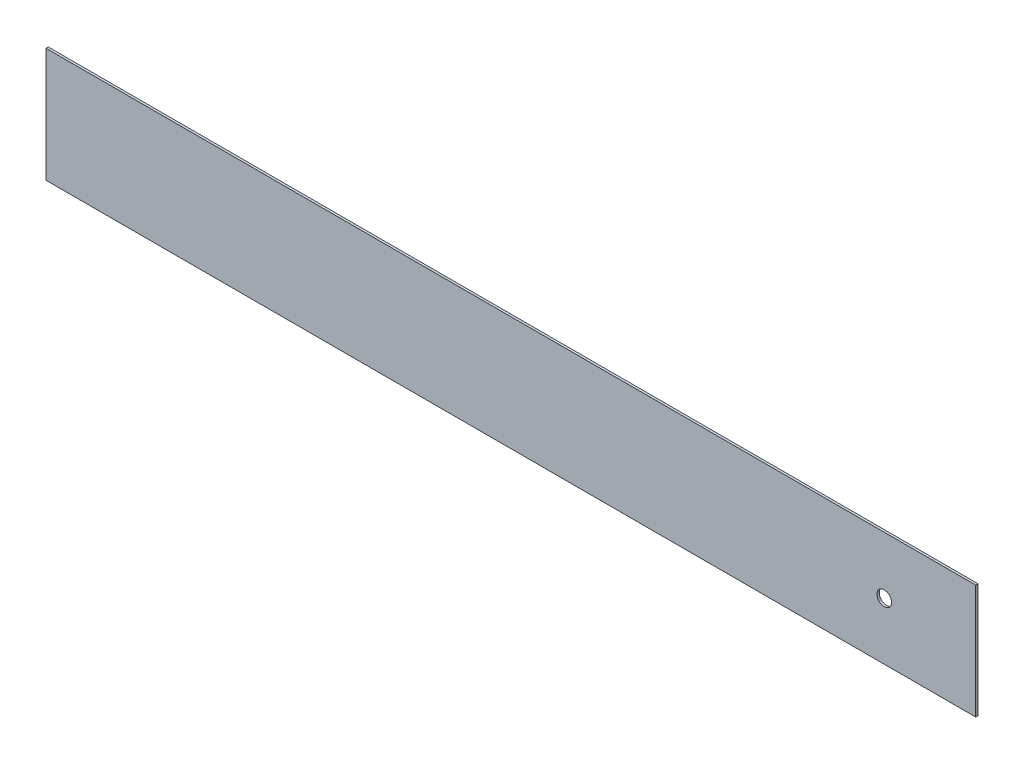
from build123d import *

# Parameters (mm, degrees)
SKETCH1_W           = 1220
SKETCH1_H           = 150
SKETCH1_R           = 9.6
BOSS_EXTRUDE1_DEPTH = 3


with BuildPart() as part:
    # Sketch1 → Boss-Extrude1 (new body)
    with BuildSketch(Plane.XY):
        Rectangle(SKETCH1_W, SKETCH1_H)
        with Locations((490, 0)):
            Circle(SKETCH1_R, mode=Mode.SUBTRACT)
    extrude(amount=BOSS_EXTRUDE1_DEPTH)


solid = part.part
